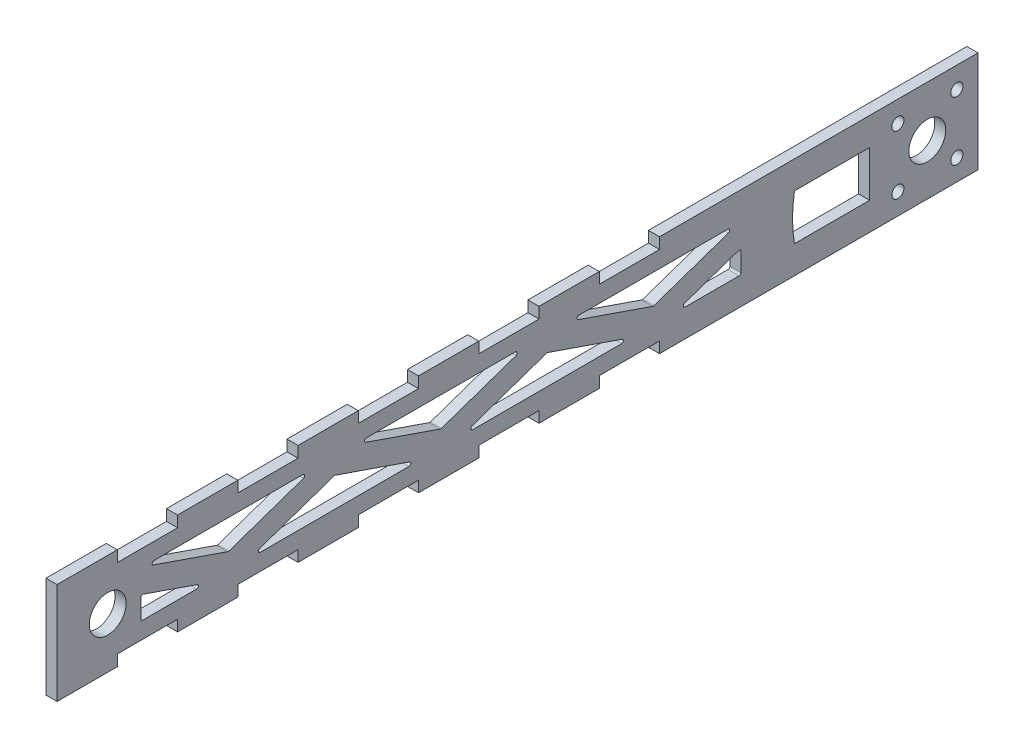
from build123d import *

# Parameters (mm, degrees)
SKETCH1_R           = 1.65
SKETCH1_R_2         = 5
BOSS_EXTRUDE1_DEPTH = 3
CUT_EXTRUDE1_DEPTH  = 3
FILLET1_R           = 0.5


with BuildPart() as part:
    # Sketch1 → Boss-Extrude1 (new body)
    with BuildSketch(Plane(origin=(0, 0, 0), x_dir=(0, 0, -1), z_dir=(1, 0, 0))):
        Polygon((-125, 13.75), (-125, -13.75), (-108.645833333, -13.75), (-108.645833333, -10.75), (-92.291666667, -10.75), (-92.291666667, -13.75), (-75.9375, -13.75), (-75.9375, -10.75), (-59.583333333, -10.75), (-59.583333333, -13.75), (-43.229166667, -13.75), (-43.229166667, -10.75), (-26.875, -10.75), (-26.875, -13.75), (-10.520833333, -13.75), (-10.520833333, -10.75), (5.833333333, -10.75), (5.833333333, -13.75), (22.1875, -13.75), (22.1875, -10.75), (38.541666667, -10.75), (38.541666667, -13.75), (125, -13.75), (125, 13.75), (38.541666667, 13.75), (38.541666667, 10.75), (22.1875, 10.75), (22.1875, 13.75), (5.833333333, 13.75), (5.833333333, 10.75), (-10.520833333, 10.75), (-10.520833333, 13.75), (-26.875, 13.75), (-26.875, 10.75), (-43.229166667, 10.75), (-43.229166667, 13.75), (-59.583333333, 13.75), (-59.583333333, 10.75), (-75.9375, 10.75), (-75.9375, 13.75), (-92.291666667, 13.75), (-92.291666667, 10.75), (-108.645833333, 10.75), (-108.645833333, 13.75), align=None)
        with Locations((103.25, -8)):
            Circle(SKETCH1_R, mode=Mode.SUBTRACT)
        with Locations((119.25, -8)):
            Circle(SKETCH1_R, mode=Mode.SUBTRACT)
        with Locations((-111.25, 0)):
            Circle(SKETCH1_R_2, mode=Mode.SUBTRACT)
        with BuildLine():
            Line((95.5778, -6.2), (75.1778, -6.2))
            ThreePointArc((75.1778, -6.2), (74.648857766, 0), (75.1778, 6.2))
            Line((75.1778, 6.2), (95.5778, 6.2))
            Line((95.5778, 6.2), (95.5778, -6.2))
        make_face(mode=Mode.SUBTRACT)
        with Locations((111.25, 0)):
            Circle(SKETCH1_R_2, mode=Mode.SUBTRACT)
        with Locations((103.25, 8)):
            Circle(SKETCH1_R, mode=Mode.SUBTRACT)
        with Locations((119.25, 8)):
            Circle(SKETCH1_R, mode=Mode.SUBTRACT)
    extrude(amount=BOSS_EXTRUDE1_DEPTH)

    # Sketch3 → Cut-Extrude1 (cut)
    with BuildSketch(Plane(origin=(3, 0, 0), x_dir=(0, 0, -1), z_dir=(1, 0, 0))):
        Polygon((-102.25, 0), (-102.25, -6.25), (-84.139910217, -6.25), align=None)
        Polygon((-55.299825543, 6.25), (-101.661655387, 6.25), (-78.480740465, -1.75), align=None)
        Polygon((-49.640655791, 1.75), (-72.821570713, -6.25), (-26.459740869, -6.25), align=None)
        Polygon((2.380343805, 6.25), (-43.981486039, 6.25), (-20.800571117, -1.75), align=None)
        Polygon((8.039513557, 1.75), (-15.141401365, -6.25), (31.220428479, -6.25), align=None)
        Polygon((60.060513153, 6.25), (13.698683309, 6.25), (36.879598231, -1.75), align=None)
        Polygon((60.648857766, 0), (42.538767983, -6.25), (60.648857766, -6.25), align=None)
    extrude(amount=-CUT_EXTRUDE1_DEPTH, mode=Mode.SUBTRACT)

    # Fillet1
    fillet1_edges = [part.edges().sort_by_distance(p)[0] for p in [
        (1.5, -1.75, 20.800571117),
        (1.5, 6.25, 43.981486039),
        (1.5, 6.25, -2.380343805),
        (1.5, 1.75, -8.039513557),
        (1.5, -6.25, -31.220428479),
        (1.5, -6.25, 15.141401365),
        (1.5, -1.75, 78.480740465),
        (1.5, 6.25, 101.661655387),
        (1.5, 6.25, 55.299825543),
        (1.5, 1.75, 49.640655791),
        (1.5, -6.25, 26.459740869),
        (1.5, -6.25, 72.821570713),
        (1.5, -6.25, -42.538767983),
        (1.5, 0, -60.648857766),
        (1.5, -6.25, -60.648857766),
        (1.5, -1.75, -36.879598231),
        (1.5, 6.25, -13.698683309),
        (1.5, 6.25, -60.060513153),
        (1.5, 0, 102.25),
        (1.5, -6.25, 84.139910217),
        (1.5, -6.25, 102.25),
    ]]
    fillet(fillet1_edges, radius=FILLET1_R)


solid = part.part
